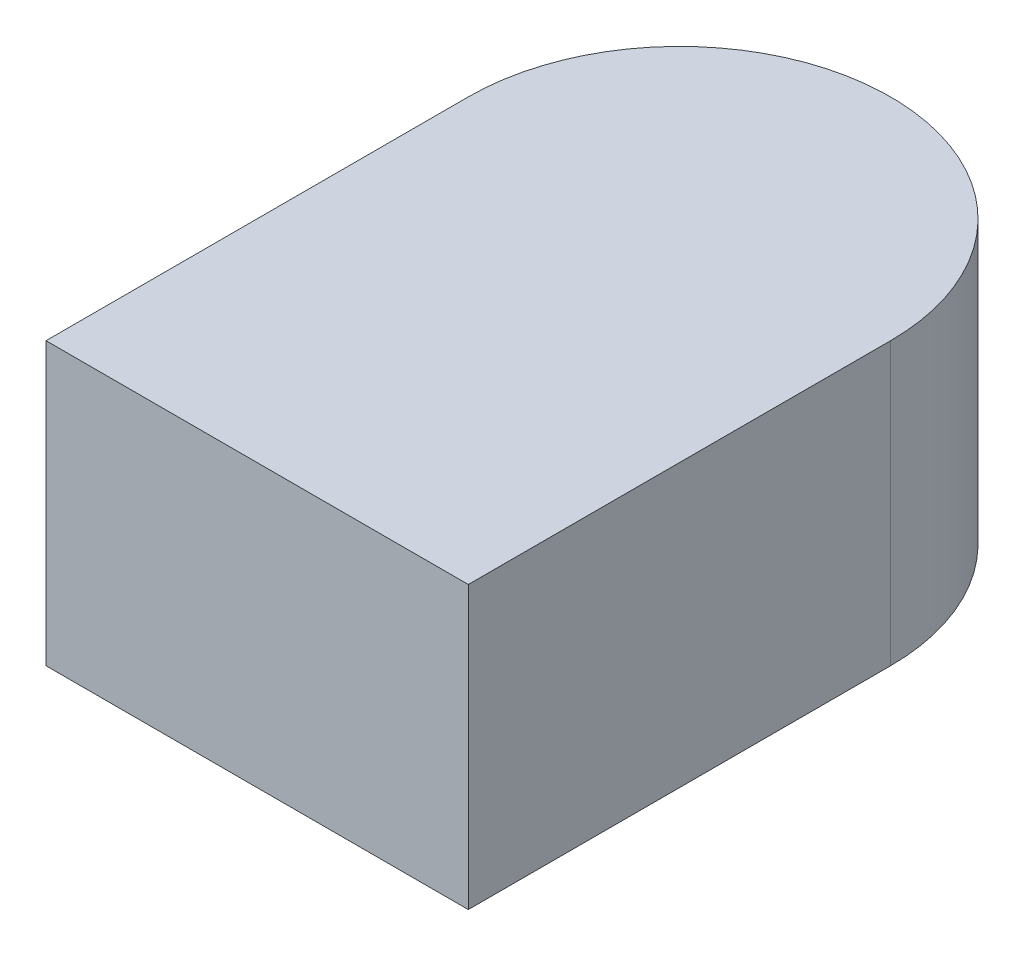
from build123d import *

# Parameters (mm, degrees)
BOSS_EXTRUDE1_DEPTH = 0.2


with BuildPart() as part:
    # Sketch1 → Boss-Extrude1 (new body)
    with BuildSketch(Plane(origin=(0, 0, 0), x_dir=(1, 0, 0), z_dir=(0, 1, 0))):
        with BuildLine():
            Line((-0.15, -0.15), (0.15, -0.15))
            Line((0.15, -0.15), (0.15, 0.15))
            ThreePointArc((0.15, 0.15), (0, 0.3), (-0.15, 0.15))
            Line((-0.15, 0.15), (-0.15, -0.15))
        make_face()
    extrude(amount=BOSS_EXTRUDE1_DEPTH)


solid = part.part
